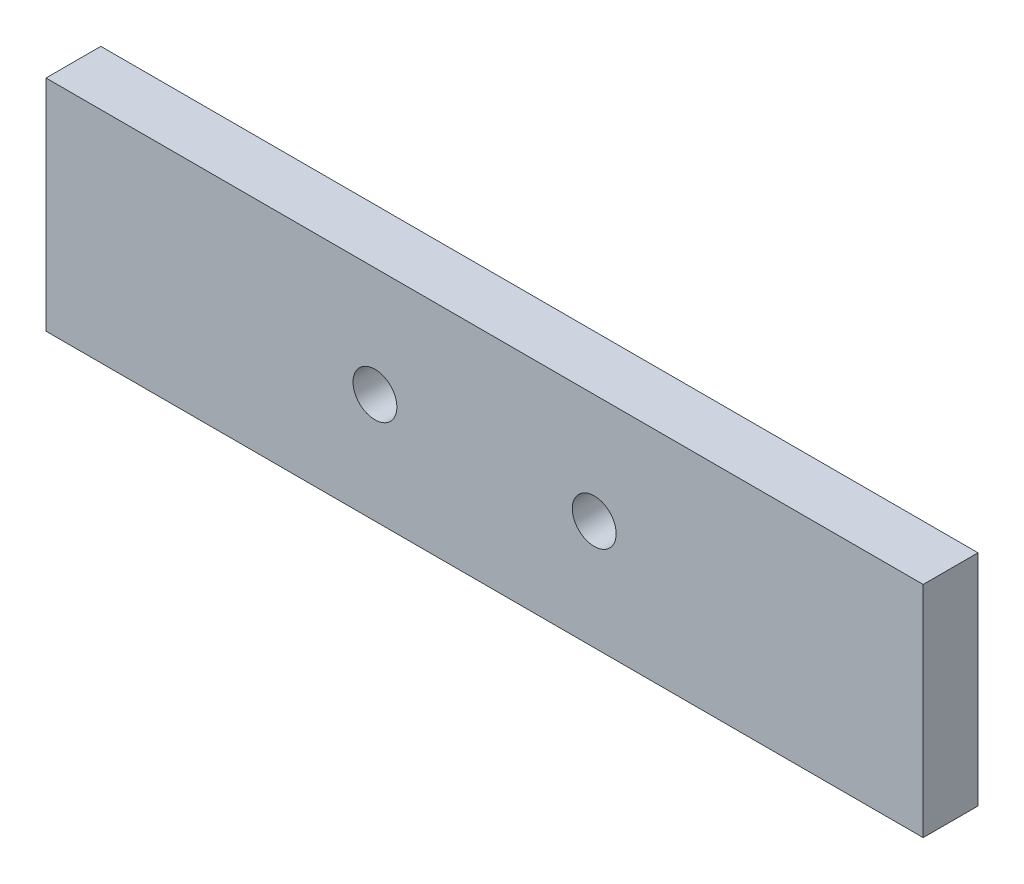
from build123d import *

# Parameters (mm, degrees)
CROQUIS1_W              = 80
CROQUIS1_H              = 20
CROQUIS1_R              = 2
CROQUIS1_R_2            = 4.05
SALIENTE_EXTRUIR2_DEPTH = 5
CROQUIS2_R              = 6
SALIENTE_EXTRUIR3_DEPTH = 2.1


with BuildPart() as part:
    # Croquis1 → Saliente-Extruir2 (new body)
    with BuildSketch(Plane.XY):
        with Locations((40, 10)):
            Rectangle(CROQUIS1_W, CROQUIS1_H)
        with Locations((30, 10)):
            Circle(CROQUIS1_R, mode=Mode.SUBTRACT)
        with Locations((50, 10)):
            Circle(CROQUIS1_R, mode=Mode.SUBTRACT)
        with Locations((8, 10)):
            Circle(CROQUIS1_R_2, mode=Mode.SUBTRACT)
        with Locations((72, 10)):
            Circle(CROQUIS1_R_2, mode=Mode.SUBTRACT)
    extrude(amount=SALIENTE_EXTRUIR2_DEPTH)

    # Croquis2 → Saliente-Extruir3 (add)
    with BuildSketch(Plane.XY.offset(5)):
        with Locations((8, 10)):
            Circle(CROQUIS2_R)
        with Locations((73, 10)):
            Circle(CROQUIS2_R)
    extrude(amount=-SALIENTE_EXTRUIR3_DEPTH)


solid = part.part
